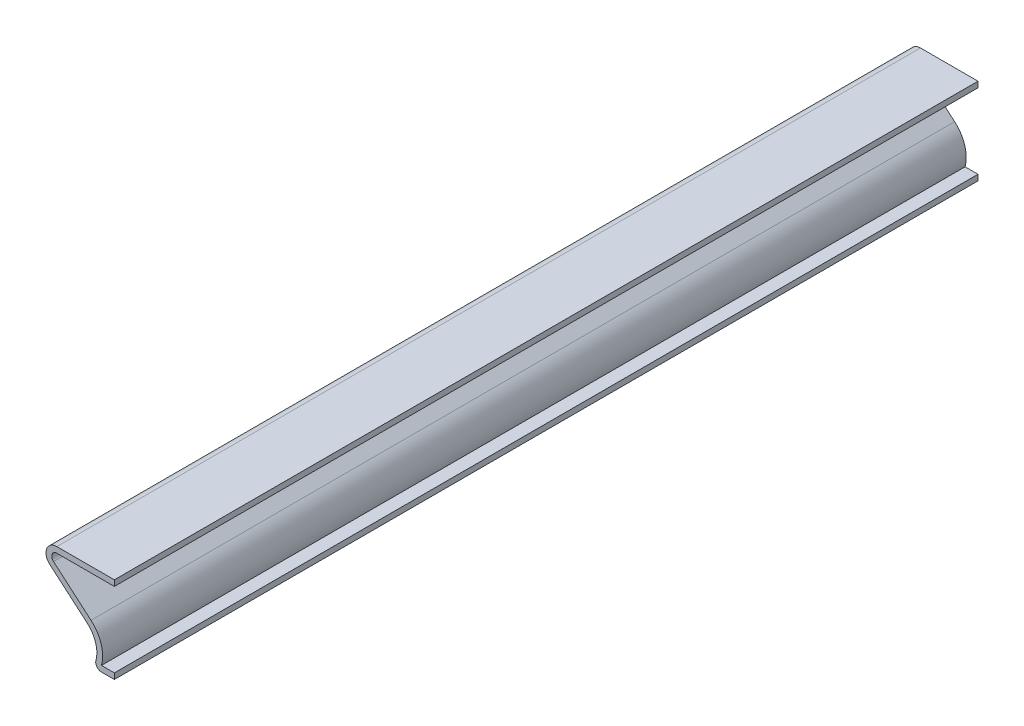
from build123d import *

# Parameters (mm, degrees)
EXTRUDE_THIN1_DEPTH = 190.5
FILLET1_R           = 1.27


with BuildPart() as part:
    # Sketch2 → Extrude-Thin1 (new body)
    with BuildSketch(Plane.XY):
        with BuildLine():
            Line((0, 19.05), (-12.7, 19.05))
            ThreePointArc((-12.7, 19.05), (-14.933416251, 17.494706059), (-14.249357426, 14.860479244))
            Line((-14.249357426, 14.860479244), (-5.98022255, 7.775342526))
            ThreePointArc((-5.98022255, 7.775342526), (-3.936796637, 4.112343257), (-4.7625, 0))
            Line((-4.7625, 0), (0, 0))
            Line((0, 0), (0, 1.27))
            Line((0, 1.27), (-2.845784509, 1.27))
            ThreePointArc((-2.845784509, 1.27), (-2.920461936, 5.33839935), (-5.153898589, 8.739753596))
            Line((-5.153898589, 8.739753596), (-13.423033466, 15.824890314))
            ThreePointArc((-13.423033466, 15.824890314), (-13.742260917, 17.054196161), (-12.7, 17.78))
            Line((-12.7, 17.78), (0, 17.78))
            Line((0, 17.78), (0, 19.05))
        make_face()
    extrude(amount=-EXTRUDE_THIN1_DEPTH)

    # Fillet1
    fillet1_edges = [part.edges().sort_by_distance(p)[0] for p in [
        (-4.7625, 0, -95.25),
    ]]
    fillet(fillet1_edges, radius=FILLET1_R)


solid = part.part
